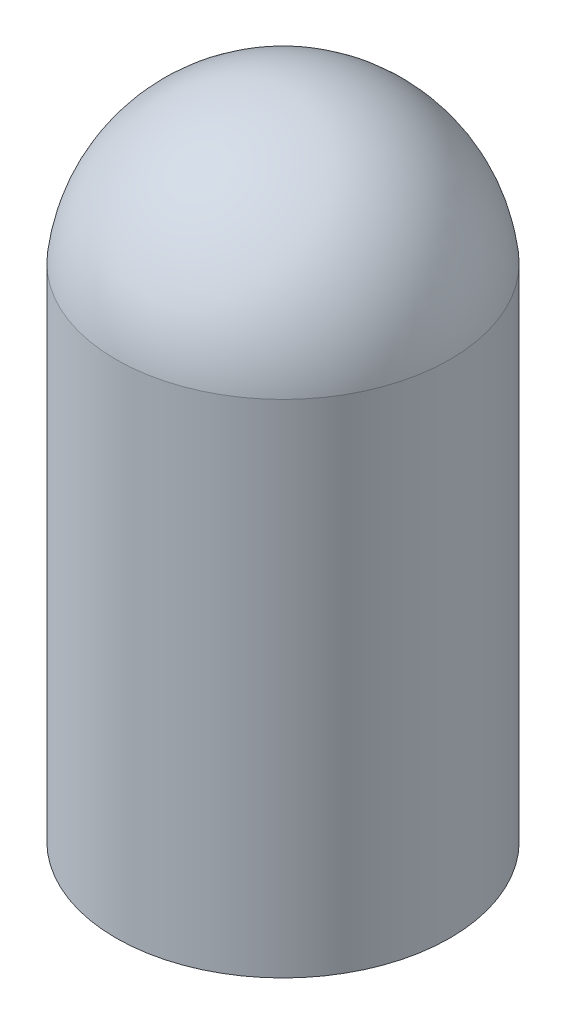
from build123d import *

# Parameters (mm, degrees)
SKETCH1_R         = 50.8
EXTRUDE1_DEPTH    = 152.4
DOME1_FACE_RADIUS = 50.8
DOME1_HEIGHT      = 45.72


with BuildPart() as part:
    # Sketch1 → Extrude1 (new body)
    with BuildSketch(Plane(origin=(0, 0, 0), x_dir=(1, 0, 0), z_dir=(0, 1, 0))):
        with Locations(Location((0, 0, 0), (0, 0, 270))):  # turned: the seam where the file's is
            Circle(SKETCH1_R)
    extrude(amount=EXTRUDE1_DEPTH)

    # Dome1: a dome of height H over a round flat face of radius A is a cap of a sphere of radius (A * A + H * H) / (2 * H)
    dome1_r = (DOME1_FACE_RADIUS * DOME1_FACE_RADIUS + DOME1_HEIGHT * DOME1_HEIGHT) / (2 * DOME1_HEIGHT)
    dome1_base = Plane((0, 152.4, 0), z_dir=(0, 1, 0))
    with Locations(dome1_base.offset(DOME1_HEIGHT - dome1_r)):
        dome1_ball = Sphere(dome1_r, mode=Mode.PRIVATE)
    add(split(dome1_ball, bisect_by=dome1_base, keep=Keep.TOP, mode=Mode.PRIVATE))


solid = part.part
